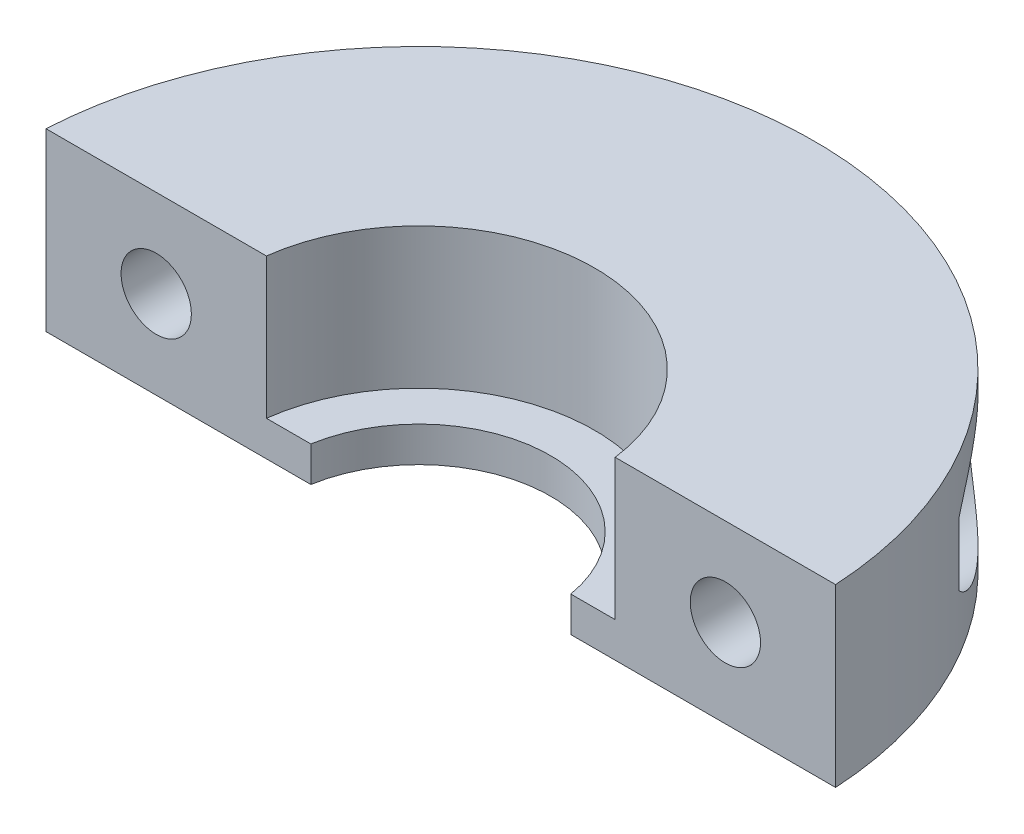
from build123d import *

# Parameters (mm, degrees)
SKETCH1_R           = 18
SKETCH1_R_2         = 8
BOSS_EXTRUDE1_DEPTH = 8
SKETCH2_R           = 8
SKETCH2_R_2         = 6
BOSS_EXTRUDE2_DEPTH = 1.6
SKETCH3_W           = 40
SKETCH3_H           = 20
CUT_EXTRUDE1_DEPTH  = 9
CUT_EXTRUDE2_REACH  = 19
SKETCH5_R           = 1.6
CUT_EXTRUDE3_REACH  = 27
CUT_EXTRUDE3_START  = -8
SKETCH6_R           = 3


with BuildPart() as part:
    # Sketch1 → Boss-Extrude1 (new body)
    with BuildSketch(Plane(origin=(0, 0, 0), x_dir=(1, 0, 0), z_dir=(0, 1, 0))):
        Circle(SKETCH1_R)
        Circle(SKETCH1_R_2, mode=Mode.SUBTRACT)
    extrude(amount=BOSS_EXTRUDE1_DEPTH)

    # Sketch2 → Boss-Extrude2 (add)
    with BuildSketch(Plane(origin=(0, 0, 0), x_dir=(1, 0, 0), z_dir=(0, 1, 0))):
        Circle(SKETCH2_R)
        Circle(SKETCH2_R_2, mode=Mode.SUBTRACT)
    extrude(amount=BOSS_EXTRUDE2_DEPTH)

    # Sketch3 → Cut-Extrude1 (cut, through all)
    with BuildSketch(Plane(origin=(0, 8, 0), x_dir=(1, 0, 0), z_dir=(0, 1, 0))):
        with Locations((0, -9)):
            Rectangle(SKETCH3_W, SKETCH3_H)
    extrude(amount=-CUT_EXTRUDE1_DEPTH, mode=Mode.SUBTRACT)

    # Sketch5 → Cut-Extrude2 (cut, up to next)
    with BuildSketch(Plane.XY.offset(-1), mode=Mode.PRIVATE) as cut_extrude2_sk1:
        with Locations((-12.954727344, 4)):
            Circle(SKETCH5_R)
    cut_extrude2_tool1 = extrude(cut_extrude2_sk1.sketch, amount=-CUT_EXTRUDE2_REACH, mode=Mode.PRIVATE) & part.part
    add(cut_extrude2_tool1.solids().sort_by_distance((-12.954727, 4, -1))[0], mode=Mode.SUBTRACT)
    # Sketch5 → Cut-Extrude2 (cut, up to next)
    with BuildSketch(Plane.XY.offset(-1), mode=Mode.PRIVATE) as cut_extrude2_sk2:
        with Locations((12.954727344, 4)):
            Circle(SKETCH5_R)
    cut_extrude2_tool2 = extrude(cut_extrude2_sk2.sketch, amount=-CUT_EXTRUDE2_REACH, mode=Mode.PRIVATE) & part.part
    add(cut_extrude2_tool2.solids().sort_by_distance((12.954727, 4, -1))[0], mode=Mode.SUBTRACT)

    # Sketch6 → Cut-Extrude3 (cut, up to next)
    with BuildSketch(Plane.XY.offset(-1).offset(CUT_EXTRUDE3_START), mode=Mode.PRIVATE) as cut_extrude3_sk1:
        with Locations((-12.954727344, 4)):
            Circle(SKETCH6_R)
    cut_extrude3_tool1 = extrude(cut_extrude3_sk1.sketch, amount=-CUT_EXTRUDE3_REACH, mode=Mode.PRIVATE) & part.part
    add(cut_extrude3_tool1.solids().sort_by_distance((-12.954727, 4, -9))[0], mode=Mode.SUBTRACT)
    # Sketch6 → Cut-Extrude3 (cut, up to next)
    with BuildSketch(Plane.XY.offset(-1).offset(CUT_EXTRUDE3_START), mode=Mode.PRIVATE) as cut_extrude3_sk2:
        with Locations((12.954727344, 4)):
            Circle(SKETCH6_R)
    cut_extrude3_tool2 = extrude(cut_extrude3_sk2.sketch, amount=-CUT_EXTRUDE3_REACH, mode=Mode.PRIVATE) & part.part
    add(cut_extrude3_tool2.solids().sort_by_distance((12.954727, 4, -9))[0], mode=Mode.SUBTRACT)


solid = part.part
